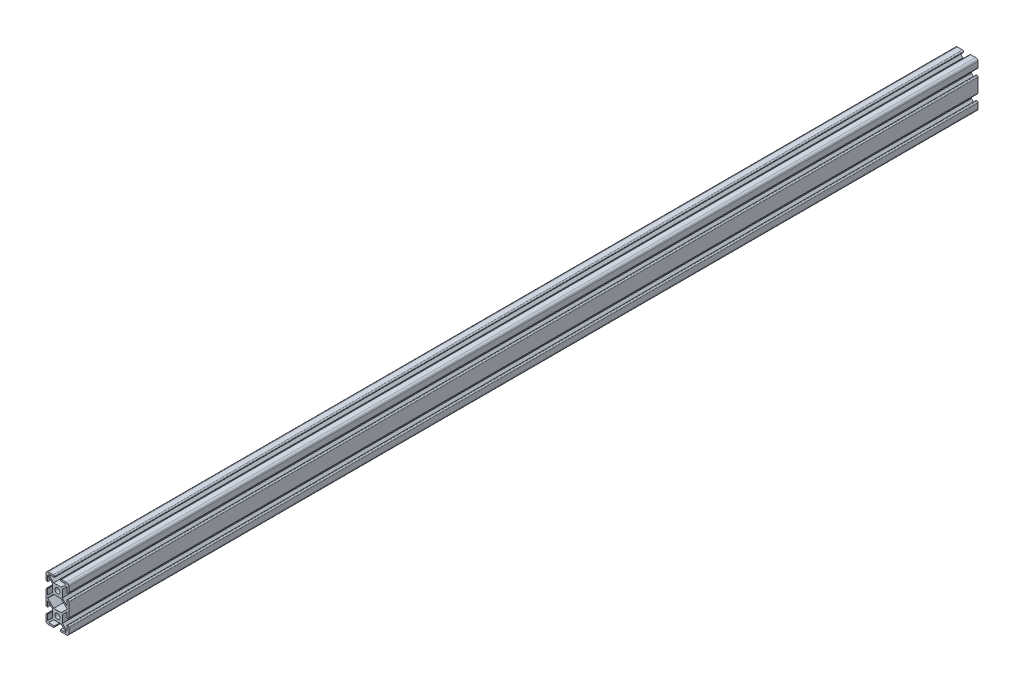
from build123d import *

# Parameters (mm, degrees)
CROQUIS1_R              = 3.35
SALIENTE_EXTRUIR1_DEPTH = 1200
REDONDEO1_R             = 1.5


with BuildPart() as part:
    # Croquis1 → Saliente-Extruir1 (new body)
    with BuildSketch(Plane.XY):
        with BuildLine():
            Line((-12.05, -30.05), (-4, -30.05))
            Line((-4, -30.05), (-4, -27.75))
            Line((-4, -27.75), (-11.7, -27.75))
            Line((-11.7, -27.75), (-5, -21.05))
            Line((-5, -21.05), (5, -21.05))
            Line((5, -21.05), (11.7, -27.75))
            Line((11.7, -27.75), (4, -27.75))
            Line((4, -27.75), (4, -30.05))
            Line((4, -30.05), (12.05, -30.05))
            ThreePointArc((12.05, -30.05), (14.171320344, -29.171320344), (15.05, -27.05))
            Line((15.05, -27.05), (15.05, -18.55))
            Line((15.05, -18.55), (12.75, -18.55))
            Line((12.75, -18.55), (12.75, -25.8))
            Line((12.75, -25.8), (6.5, -19.55))
            Line((6.5, -19.55), (6.5, -9.55))
            Line((6.5, -9.55), (12.75, -3.3))
            Line((12.75, -3.3), (12.75, -10.55))
            Line((12.75, -10.55), (15.05, -10.55))
            Line((15.05, -10.55), (15.05, 10.55))
            Line((15.05, 10.55), (12.75, 10.55))
            Line((12.75, 10.55), (12.75, 3.3))
            Line((12.75, 3.3), (6.5, 9.55))
            Line((6.5, 9.55), (6.5, 19.55))
            Line((6.5, 19.55), (12.75, 25.8))
            Line((12.75, 25.8), (12.75, 18.55))
            Line((12.75, 18.55), (15.05, 18.55))
            Line((15.05, 18.55), (15.05, 27.05))
            ThreePointArc((15.05, 27.05), (14.171320344, 29.171320344), (12.05, 30.05))
            Line((12.05, 30.05), (4, 30.05))
            Line((4, 30.05), (4, 27.75))
            Line((4, 27.75), (11.7, 27.75))
            Line((11.7, 27.75), (5, 21.05))
            Line((5, 21.05), (-5, 21.05))
            Line((-5, 21.05), (-11.7, 27.75))
            Line((-11.7, 27.75), (-4, 27.75))
            Line((-4, 27.75), (-4, 30.05))
            Line((-4, 30.05), (-12.05, 30.05))
            ThreePointArc((-12.05, 30.05), (-14.171320344, 29.171320344), (-15.05, 27.05))
            Line((-15.05, 27.05), (-15.05, 18.55))
            Line((-15.05, 18.55), (-12.75, 18.55))
            Line((-12.75, 18.55), (-12.75, 25.8))
            Line((-12.75, 25.8), (-6.5, 19.55))
            Line((-6.5, 19.55), (-6.5, 9.55))
            Line((-6.5, 9.55), (-12.75, 3.3))
            Line((-12.75, 3.3), (-12.75, 10.55))
            Line((-12.75, 10.55), (-15.05, 10.55))
            Line((-15.05, 10.55), (-15.05, -10.55))
            Line((-15.05, -10.55), (-12.75, -10.55))
            Line((-12.75, -10.55), (-12.75, -3.3))
            Line((-12.75, -3.3), (-6.5, -9.55))
            Line((-6.5, -9.55), (-6.5, -19.55))
            Line((-6.5, -19.55), (-12.75, -25.8))
            Line((-12.75, -25.8), (-12.75, -18.55))
            Line((-12.75, -18.55), (-15.05, -18.55))
            Line((-15.05, -18.55), (-15.05, -27.05))
            ThreePointArc((-15.05, -27.05), (-14.171320344, -29.171320344), (-12.05, -30.05))
        make_face()
        with Locations((0, 14.55)):
            Circle(CROQUIS1_R, mode=Mode.SUBTRACT)
        with Locations((0, -14.55)):
            Circle(CROQUIS1_R, mode=Mode.SUBTRACT)
        Polygon((-5, 8.05), (5, 8.05), (11.7, 1.35), (12.75, 0.3), (12.75, -0.3), (11.7, -1.35), (5, -8.05), (-5, -8.05), (-11.7, -1.35), (-12.75, -0.3), (-12.75, 0.3), (-11.7, 1.35), align=None, mode=Mode.SUBTRACT)
    extrude(amount=SALIENTE_EXTRUIR1_DEPTH)

    # Redondeo1
    redondeo1_edges = [part.edges().sort_by_distance(p)[0] for p in [
        (-4, 30.05, 600),
        (4, 30.05, 600),
        (15.05, 18.55, 600),
        (15.05, 10.55, 600),
        (15.05, -10.55, 600),
        (15.05, -18.55, 600),
        (4, -30.05, 600),
        (-4, -30.05, 600),
        (-15.05, -18.55, 600),
        (-15.05, -10.55, 600),
        (-15.05, 10.55, 600),
        (-15.05, 18.55, 600),
    ]]
    fillet(redondeo1_edges, radius=REDONDEO1_R)


solid = part.part
